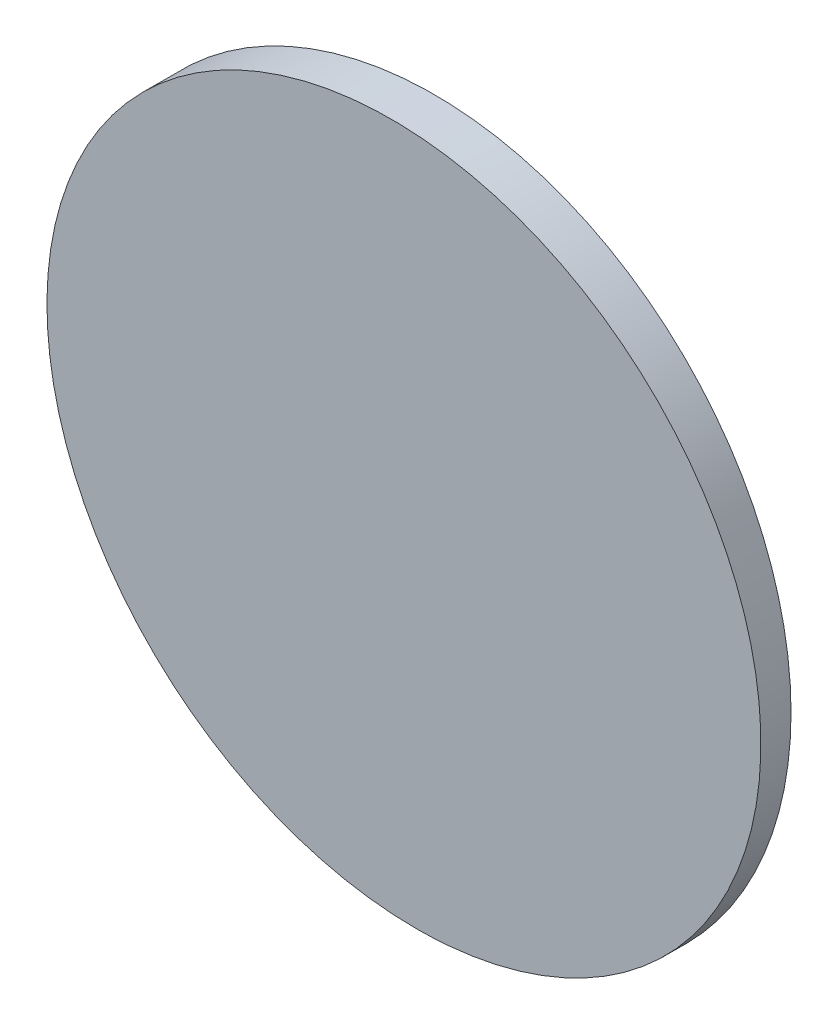
from build123d import *

# Parameters (mm, degrees)
SKETCH_2_R          = 50
EXTRUDE_1_DEPTH     = 6
CUT_EXTRUDE_1_DEPTH = 50


with BuildPart() as part:
    # 草图2 → 凸台-拉伸1 (new body)
    with BuildSketch(Plane.XY):
        Circle(SKETCH_2_R)
    extrude(amount=EXTRUDE_1_DEPTH)

    # 草图3 → 切除-拉伸1 (cut, symmetric)
    with BuildSketch(Plane(origin=(0, 0, 0), x_dir=(0, 0, -1), z_dir=(1, 0, 0))):
        Polygon((-6, -50), (-6, 50), (-2.507923051, -50), align=None)
    extrude(amount=CUT_EXTRUDE_1_DEPTH, both=True, mode=Mode.SUBTRACT)


solid = part.part
